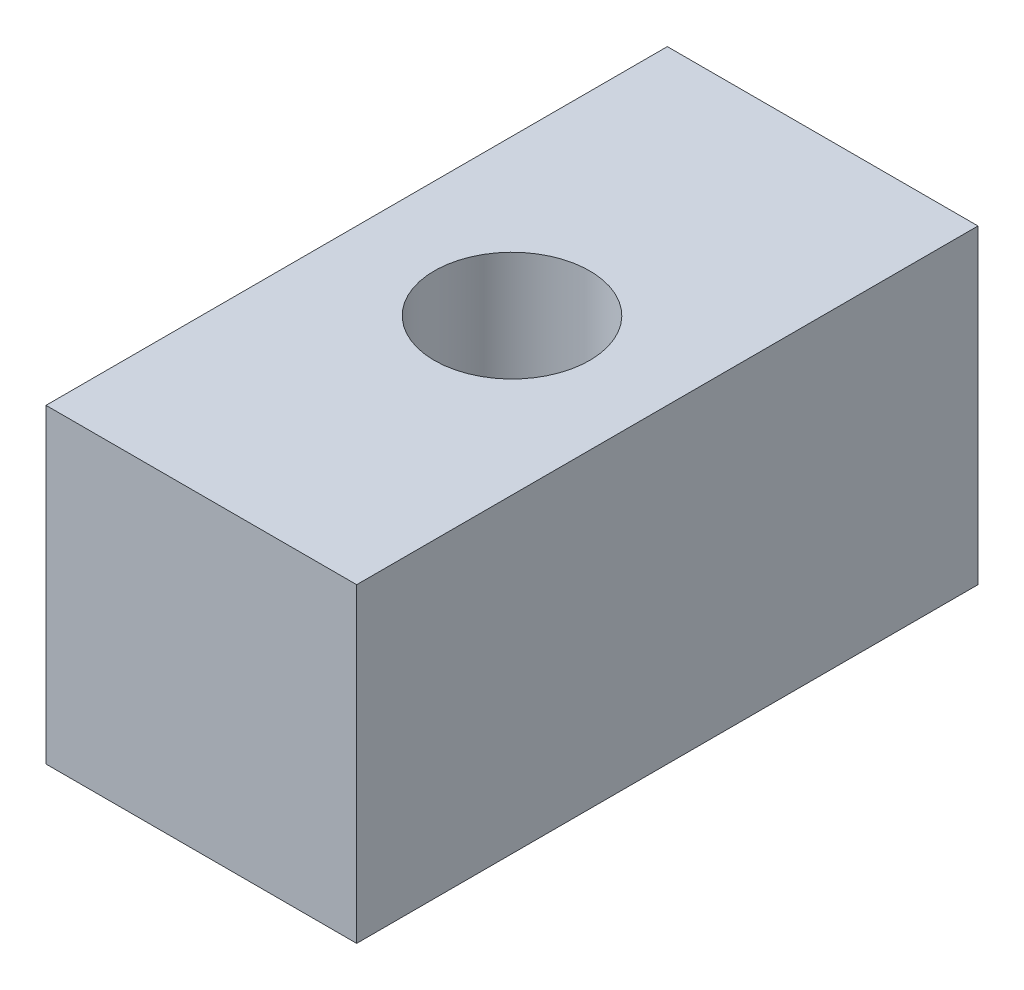
from build123d import *

# Parameters (mm, degrees)
SKETCH1_W           = 25.4
SKETCH1_H           = 50.8
BOSS_EXTRUDE1_DEPTH = 25.4
CUT_EXTRUDE1_REACH  = 27.4
SKETCH2_R           = 6.35


with BuildPart() as part:
    # Sketch1 → Boss-Extrude1 (new body)
    with BuildSketch(Plane(origin=(0, 0, 0), x_dir=(1, 0, 0), z_dir=(0, 1, 0))):
        Rectangle(SKETCH1_W, SKETCH1_H)
    extrude(amount=BOSS_EXTRUDE1_DEPTH)

    # Sketch2 → Cut-Extrude1 (cut, up to next)
    with BuildSketch(Plane(origin=(0, 25.4, 0), x_dir=(1, 0, 0), z_dir=(0, 1, 0)), mode=Mode.PRIVATE) as cut_extrude1_sk1:
        Circle(SKETCH2_R)
    cut_extrude1_tool1 = extrude(cut_extrude1_sk1.sketch, amount=-CUT_EXTRUDE1_REACH, mode=Mode.PRIVATE) & part.part
    add(cut_extrude1_tool1.solids().sort_by_distance((0, 25.4, 0))[0], mode=Mode.SUBTRACT)


solid = part.part
